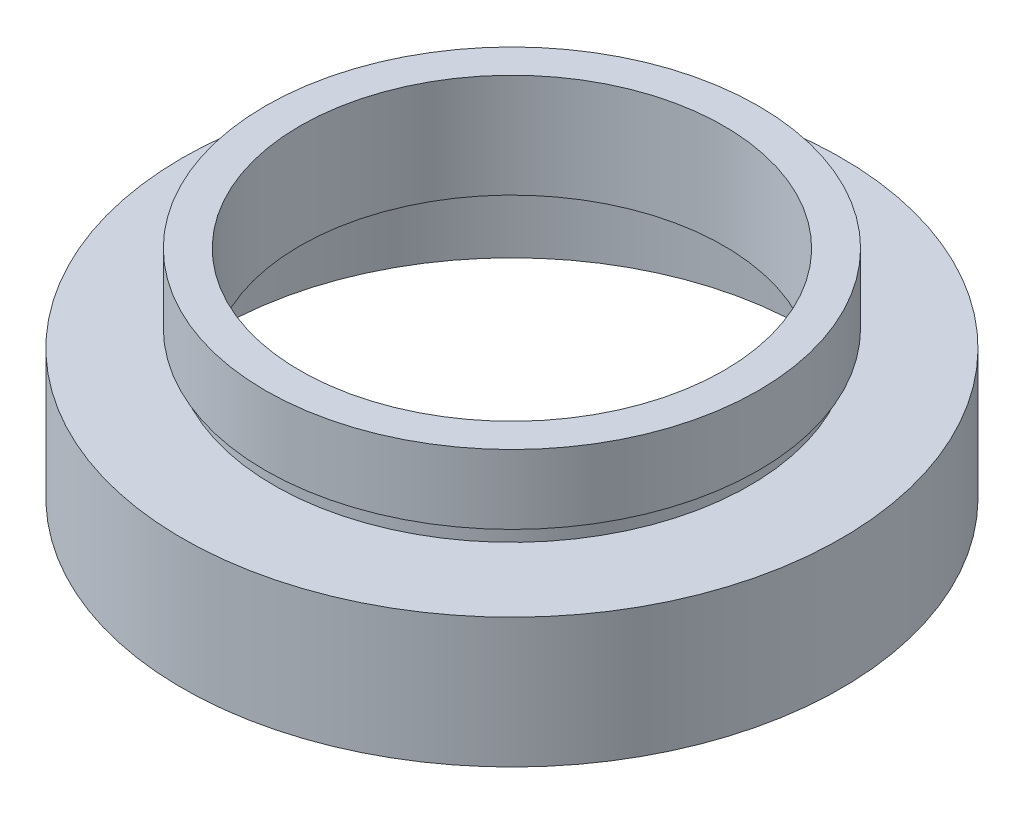
from build123d import *


with BuildPart() as part:
    # 草图1 → 旋转1 (revolve)
    with BuildSketch(Plane.XY, mode=Mode.PRIVATE) as revolve_1_sk:
        Polygon((17, 0), (17, 5.5), (17.6, 5.5), (17.6, 6.5), (12.25, 6.5), (12.25, 12.5), (14.25, 12.5), (14.25, 8.5), (13.75, 8.5), (13.75, 7.5), (19.05, 7.5), (19.05, 0), align=None)
    revolve(revolve_1_sk.sketch.rotate(Axis((0, 16.886018237, 0), (0, -1, 0)), 180), axis=Axis((0, 16.886018237, 0), (0, -1, 0)))  # turned: the seam where the file's is


solid = part.part
